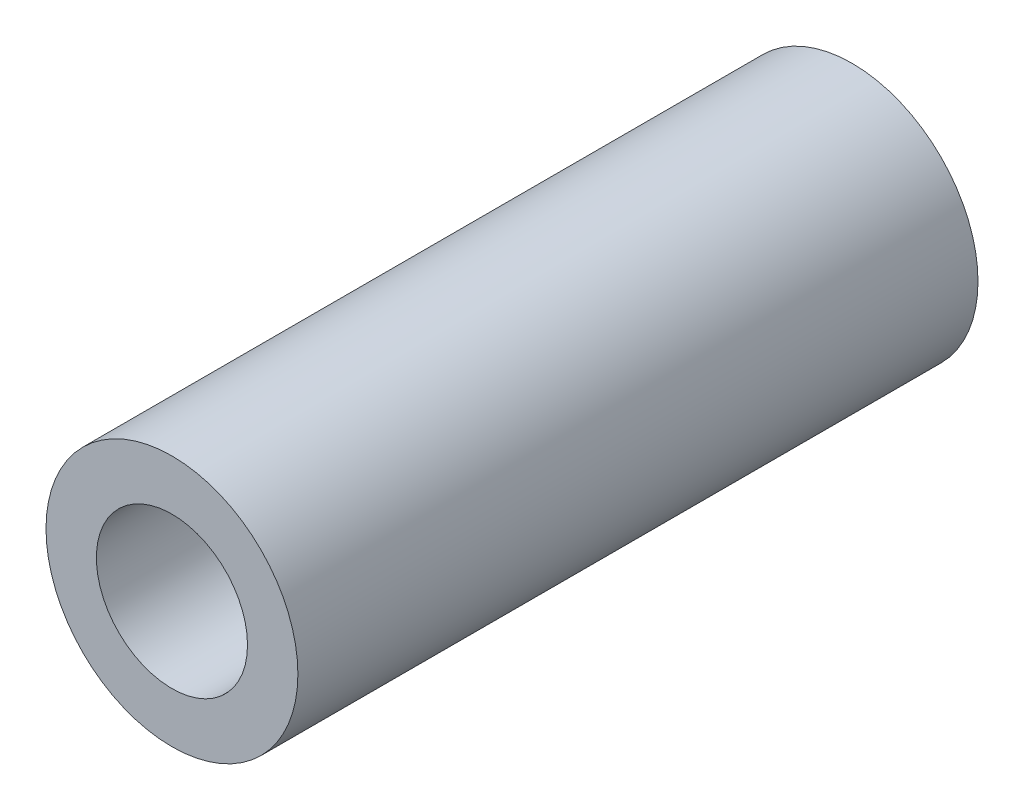
from build123d import *

# Parameters (mm, degrees)
ESBO_O1_R                = 5
ESBO_O1_R_2              = 3
RESSALTO_EXTRUS_O1_DEPTH = 27


with BuildPart() as part:
    # Esboço1 → Ressalto-extrusão1 (new body)
    with BuildSketch(Plane.XY):
        Circle(ESBO_O1_R)
        Circle(ESBO_O1_R_2, mode=Mode.SUBTRACT)
    extrude(amount=RESSALTO_EXTRUS_O1_DEPTH)


solid = part.part
